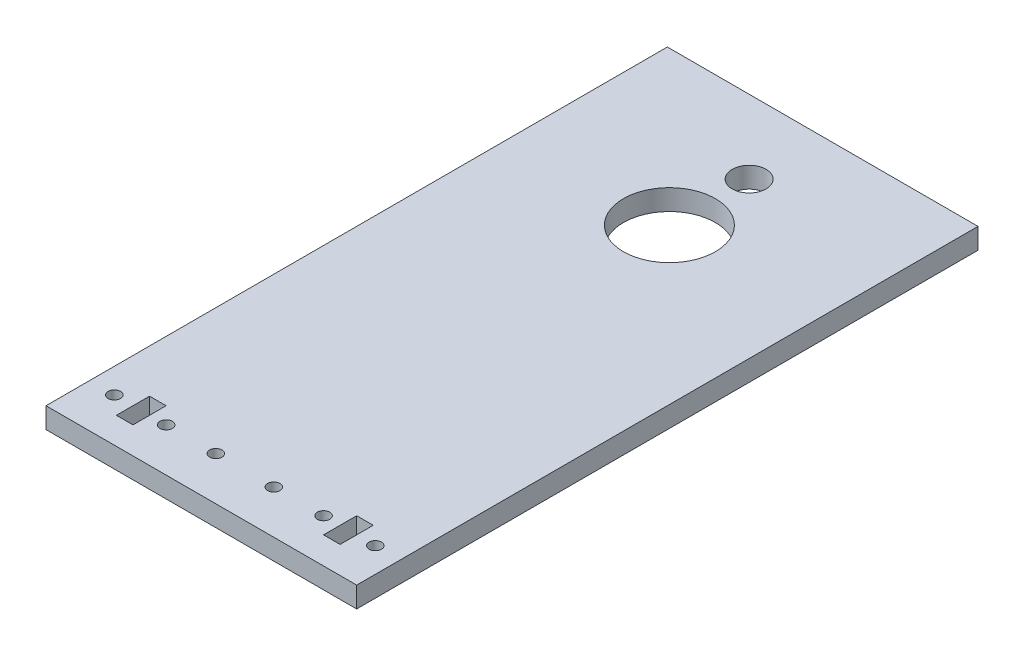
from build123d import *

# Parameters (mm, degrees)
SKETCH_1_R      = 1.5
SKETCH_1_W      = 4
SKETCH_1_H      = 8
SKETCH_1_R_2    = 4.1
SKETCH_1_R_3    = 11.1
EXTRUDE_6_DEPTH = 5


with BuildPart() as part:
    # 草图1 → 凸台-拉伸6 (new body)
    with BuildSketch(Plane(origin=(0, 0, 0), x_dir=(1, 0, 0), z_dir=(0, 1, 0))):
        Polygon((75, 150), (37.5, 150), (0, 150), (0, 0), (75, 0), align=None)
        with Locations((6, 10.5)):
            Circle(SKETCH_1_R, mode=Mode.SUBTRACT)
        with Locations((12.5, 10.5)):
            Rectangle(SKETCH_1_W, SKETCH_1_H, mode=Mode.SUBTRACT)
        with Locations((18.5, 10.5)):
            Circle(SKETCH_1_R, mode=Mode.SUBTRACT)
        with Locations((30.5, 10.5)):
            Circle(SKETCH_1_R, mode=Mode.SUBTRACT)
        with Locations((44.5, 10.5)):
            Circle(SKETCH_1_R, mode=Mode.SUBTRACT)
        with Locations((56.5, 10.5)):
            Circle(SKETCH_1_R, mode=Mode.SUBTRACT)
        with Locations((62.5, 10.5)):
            Rectangle(SKETCH_1_W, SKETCH_1_H, mode=Mode.SUBTRACT)
        with Locations((69, 10.5)):
            Circle(SKETCH_1_R, mode=Mode.SUBTRACT)
        with Locations((37.5, 132.25)):
            Circle(SKETCH_1_R_2, mode=Mode.SUBTRACT)
        with Locations((37.5, 113)):
            Circle(SKETCH_1_R_3, mode=Mode.SUBTRACT)
    extrude(amount=EXTRUDE_6_DEPTH)


solid = part.part
